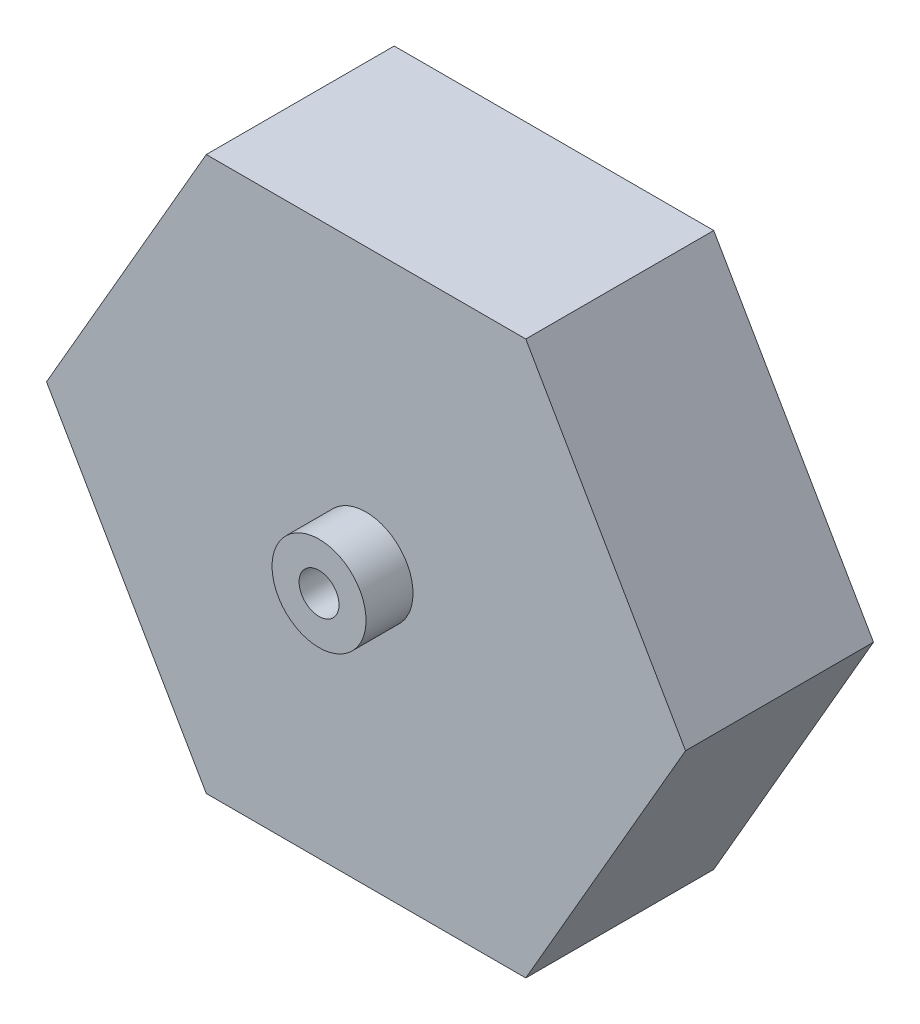
from build123d import *

# Parameters (mm, degrees)
BOSS_EXTRUDE1_DEPTH = 4
SKETCH2_R           = 1
SKETCH2_R_2         = 0.425
BOSS_EXTRUDE2_DEPTH = 1
SKETCH6_R           = 0.425
CUT_EXTRUDE1_DEPTH  = 63


with BuildPart() as part:
    # Sketch1 → Boss-Extrude1 (new body)
    with BuildSketch(Plane.XY):
        Polygon((3.4, 0), (-3.4, 0), (-6.8, -5.888972746), (-3.4, -11.777945491), (3.4, -11.777945491), (6.8, -5.888972746), align=None)
    extrude(amount=BOSS_EXTRUDE1_DEPTH)

    # Sketch2 → Boss-Extrude2 (add)
    with BuildSketch(Plane.XY.offset(4)):
        with Locations((0, -5.888972746)):
            Circle(SKETCH2_R)
        with Locations((0, -5.888972746)):
            Circle(SKETCH2_R_2, mode=Mode.SUBTRACT)
    extrude(amount=BOSS_EXTRUDE2_DEPTH)

    # Sketch6 → Cut-Extrude1 (cut)
    with BuildSketch(Plane.XY.offset(4)):
        with Locations((0, -5.888972746)):
            Circle(SKETCH6_R)
    extrude(amount=-CUT_EXTRUDE1_DEPTH, mode=Mode.SUBTRACT)


solid = part.part
